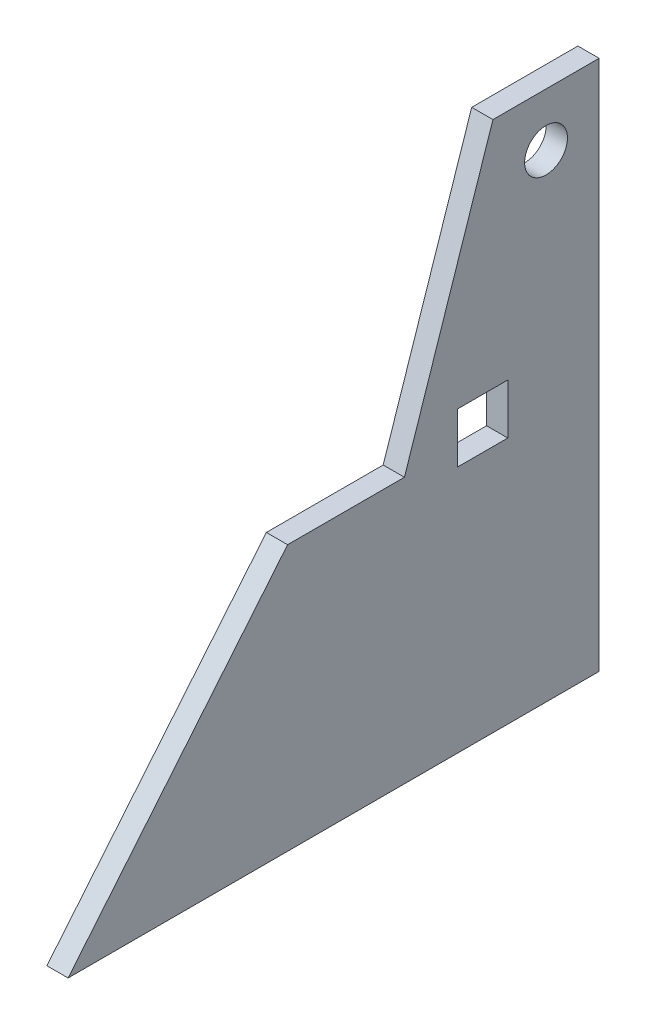
from build123d import *

# Parameters (mm, degrees)
SKETCH1_R           = 6.05
SKETCH1_W           = 14.2
SKETCH1_H           = 14.2
BOSS_EXTRUDE1_DEPTH = 6


with BuildPart() as part:
    # Sketch1 → Boss-Extrude1 (new body)
    with BuildSketch(Plane(origin=(0, 0, 0), x_dir=(0, 0, -1), z_dir=(1, 0, 0))):
        Polygon((-150, 0), (-88, 75), (-55, 75), (-30, 150), (0, 150), (0, 0), align=None)
        with Locations((-15, 135)):
            Circle(SKETCH1_R, mode=Mode.SUBTRACT)
        with Locations((-32.9, 77.1)):
            Rectangle(SKETCH1_W, SKETCH1_H, mode=Mode.SUBTRACT)
    extrude(amount=BOSS_EXTRUDE1_DEPTH)


solid = part.part
